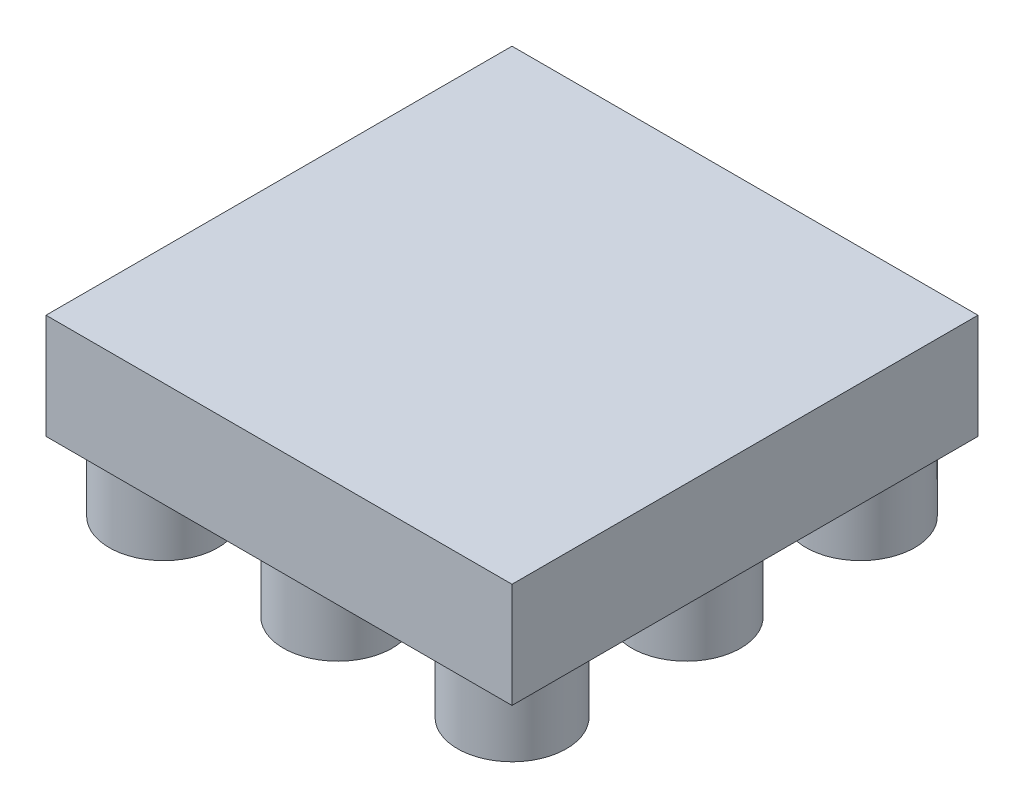
from build123d import *

# Parameters (mm, degrees)
SKETCH3_W           = 10.7
SKETCH3_H           = 10.7
BOSS_EXTRUDE2_DEPTH = 2.41
SKETCH5_R           = 1.25
BOSS_EXTRUDE3_DEPTH = 1.5875


with BuildPart() as part:
    # Sketch3 → Boss-Extrude2 (new body)
    with BuildSketch(Plane(origin=(0, 1.5875, 0), x_dir=(-1, 0, 0), z_dir=(0, 1, 0))):
        with Locations((-12.36, -20.96)):
            Rectangle(SKETCH3_W, SKETCH3_H)
    extrude(amount=BOSS_EXTRUDE2_DEPTH)

    # Sketch5 → Boss-Extrude3 (add)
    with BuildSketch(Plane.XZ.offset(-1.5875)):
        with Locations((16.36, -24.96)):
            Circle(SKETCH5_R)
        with Locations((12.36, -24.96)):
            Circle(SKETCH5_R)
        with Locations((8.36, -24.96)):
            Circle(SKETCH5_R)
        with Locations((16.36, -20.96)):
            Circle(SKETCH5_R)
        with Locations((12.36, -20.96)):
            Circle(SKETCH5_R)
        with Locations((8.36, -20.96)):
            Circle(SKETCH5_R)
        with Locations((16.36, -16.96)):
            Circle(SKETCH5_R)
        with Locations((12.36, -16.96)):
            Circle(SKETCH5_R)
        with Locations((8.36, -16.96)):
            Circle(SKETCH5_R)
    extrude(amount=BOSS_EXTRUDE3_DEPTH)


solid = part.part
